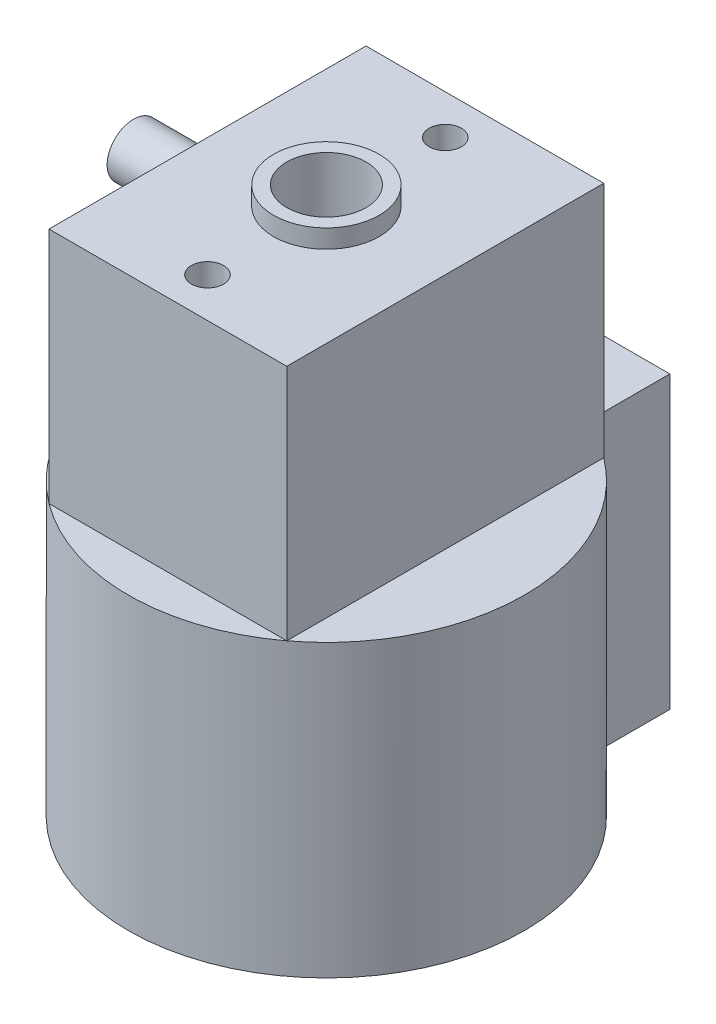
from build123d import *

# Parameters (mm, degrees)
SKETCH1_W          = 10
SKETCH1_H          = 2.5
EXTRUSION3_DEPTH   = 20
SKETCH1_R          = 7.5
SKETCH1_R_2        = 1.5
EXTRUSION3_2_DEPTH = 20
SKETCH2_W          = 30
SKETCH2_H          = 30
SKETCH2_W_2        = 9
SKETCH2_H_2        = 12
EXTRUSION4_DEPTH   = 9
SKETCH3_R          = 1
EXTRUSION5_DEPTH   = 9
HOLE1_AT_2_COUNT   = 2
HOLE1_AT_2_PITCH   = 9
SKETCH6_R          = 3
SKETCH6_R_2        = 1.5
EXTRUSION6_DEPTH   = 1
SKETCH7_R          = 2
SKETCH7_R_2        = 1.5
EXTRUSION7_DEPTH   = 0.7


with BuildPart() as part:
    # Sketch1 → Extrusion3 (new body)
    with BuildSketch(Plane(origin=(0, 0, 0), x_dir=(-1, 0, 0), z_dir=(0, 1, 0))):
        with Locations((2, -8.75)):
            Rectangle(SKETCH1_W, SKETCH1_H)
    extrude(amount=EXTRUSION3_DEPTH)


with BuildPart() as body_2:
    # Sketch1 → Extrusion3 2 (new body)
    with BuildSketch(Plane(origin=(0, 0, 0), x_dir=(-1, 0, 0), z_dir=(0, 1, 0))):
        Circle(SKETCH1_R)
        Circle(SKETCH1_R_2, mode=Mode.SUBTRACT)
    extrude(amount=EXTRUSION3_2_DEPTH)


with BuildPart() as extrusion4_tool:
    # Sketch2 → Extrusion4 (new body)
    with BuildSketch(Plane(origin=(0, 20, 0), x_dir=(1, 0, 0), z_dir=(0, 1, 0))):
        Rectangle(SKETCH2_W, SKETCH2_H)
        Rectangle(SKETCH2_W_2, SKETCH2_H_2, mode=Mode.SUBTRACT)
    extrude(amount=-EXTRUSION4_DEPTH)


with BuildPart() as part_1:
    add(part.part)

    # Extrusion4: cut by extrusion4_tool
    add(extrusion4_tool.part, mode=Mode.SUBTRACT)

    # Sketch3 → Extrusion5 (add)
    with BuildSketch(Plane.ZY.offset(7)):
        with Locations((-8.7, 9.5)):
            Circle(SKETCH3_R)
        with Locations((-8.7, 7)):
            Circle(SKETCH3_R)
        with Locations((-8.7, 4.5)):
            Circle(SKETCH3_R)
        with Locations((-8.7, 2)):
            Circle(SKETCH3_R)
    extrude(amount=EXTRUSION5_DEPTH)


with BuildPart() as body_2_1:
    add(body_2.part)

    # Extrusion4: cut by extrusion4_tool
    add(extrusion4_tool.part, mode=Mode.SUBTRACT)

    # Sketch4 → Hole1 (revolve, cut)
    with BuildSketch(Plane(origin=(0, 20, 4.5), x_dir=(0, 0, 1), z_dir=(1, 0, 0))):
        Polygon((0, 0), (0, 5.666825408), (0.6105, 5.3), (0.6105, 0), align=None)
    hole1 = revolve(axis=Axis((0, 24.244199587, 4.5), (0, -1, 0)), mode=Mode.SUBTRACT)

    # Hole1 at 2: Hole1 ×2
    with Locations(*[(0, 0, -i * HOLE1_AT_2_PITCH) for i in range(1, HOLE1_AT_2_COUNT)]):
        add(hole1, mode=Mode.SUBTRACT)

    # Sketch6 → Extrusion6 (add)
    with BuildSketch(Plane.XZ):
        Circle(SKETCH6_R)
        Circle(SKETCH6_R_2, mode=Mode.SUBTRACT)
    extrude(amount=EXTRUSION6_DEPTH)

    # Sketch7 → Extrusion7 (add)
    with BuildSketch(Plane(origin=(0, 20, 0), x_dir=(1, 0, 0), z_dir=(0, 1, 0))):
        Circle(SKETCH7_R)
        Circle(SKETCH7_R_2, mode=Mode.SUBTRACT)
    extrude(amount=EXTRUSION7_DEPTH)


solid = Compound([part_1.part, body_2_1.part])
